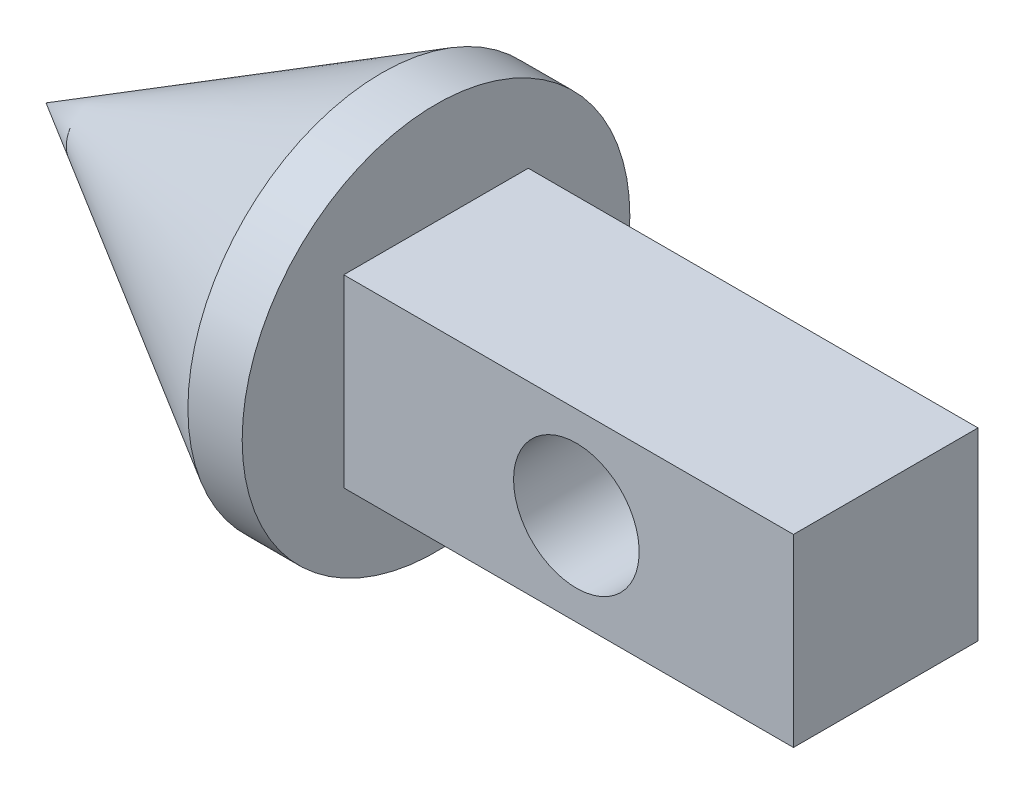
from build123d import *

# Parameters (mm, degrees)
SKETCH1_W                      = 11.9
SKETCH1_H                      = 11.9
BOSS_EXTRUDE1_DEPTH            = 29
CUT_EXTRUDE1_REACH             = 13.9
SKETCH2_R                      = 4.05
CUT_EXTRUDE1_DIRECTION_2_DEPTH = 1
SKETCH3_R                      = 12.5
BOSS_EXTRUDE2_DEPTH            = 3.5


with BuildPart() as part:
    # Sketch1 → Boss-Extrude1 (new body)
    with BuildSketch(Plane(origin=(0, 0, 0), x_dir=(0, 0, -1), z_dir=(1, 0, 0))):
        Rectangle(SKETCH1_W, SKETCH1_H)
    extrude(amount=BOSS_EXTRUDE1_DEPTH)

    # Sketch2 → Cut-Extrude1 (cut, up to next)
    with BuildSketch(Plane.XY.offset(5.95), mode=Mode.PRIVATE) as cut_extrude1_sk1:
        with Locations((15, 0)):
            Circle(SKETCH2_R)
    cut_extrude1_tool1 = extrude(cut_extrude1_sk1.sketch, amount=-CUT_EXTRUDE1_REACH, mode=Mode.PRIVATE) & part.part
    add(cut_extrude1_tool1.solids().sort_by_distance((15, 0, 5.95))[0], mode=Mode.SUBTRACT)

    # Sketch2 → Cut-Extrude1 direction 2 (cut)
    with BuildSketch(Plane.XY.offset(5.95)):
        with Locations((15, 0)):
            Circle(SKETCH2_R)
    extrude(amount=CUT_EXTRUDE1_DIRECTION_2_DEPTH, mode=Mode.SUBTRACT)

    # Sketch3 → Boss-Extrude2 (add)
    with BuildSketch(Plane.ZY):
        Circle(SKETCH3_R)
    extrude(amount=BOSS_EXTRUDE2_DEPTH)

    # Sketch4 → Revolve1 (revolve)
    with BuildSketch(Plane.XY):
        Polygon((-3.5, 0), (-3.5, 12.5), (-25.150635095, 0), align=None)
    revolve(axis=Axis((0, 0, 0), (-1, 0, 0)))


solid = part.part
